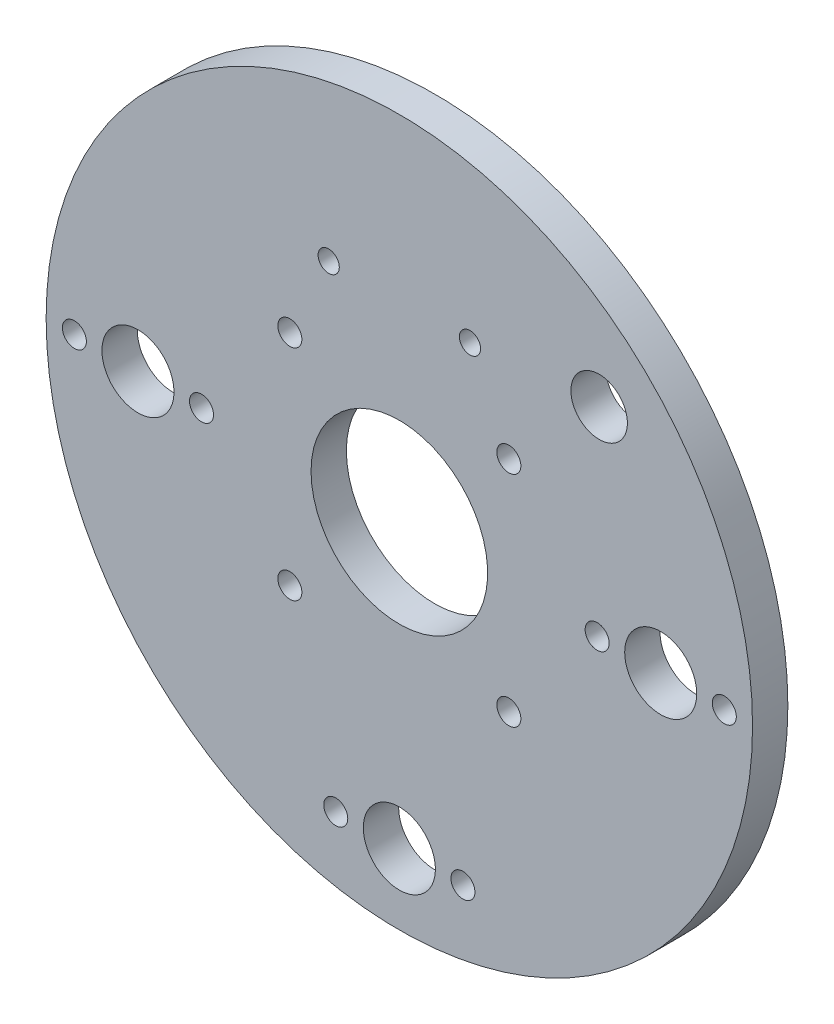
from build123d import *

# Parameters (mm, degrees)
SKETCH1_R                    = 50
BOSS_EXTRUDE1_DEPTH          = 5
F_25_0_25_DIAMETER_HOLE1_D   = 25
F_10_2_10_2_DIAMETER_HOLE1_D = 10.2
M3_CLEARANCE_HOLE1_D         = 3.4
M3_CLEARANCE_HOLE2_D         = 3.4
SKETCH11_R                   = 1.5
CUT_EXTRUDE1_DEPTH           = 10
SKETCH12_R                   = 4
CUT_EXTRUDE2_DEPTH           = 10


with BuildPart() as part:
    # Sketch1 → Boss-Extrude1 (new body)
    with BuildSketch(Plane.XY):
        Circle(SKETCH1_R)
    extrude(amount=BOSS_EXTRUDE1_DEPTH)

    # Ø25.0 (25) Diameter Hole1 (through all)
    with Locations(Plane(origin=(0, 0, 0), x_dir=(-1, 0, 0), z_dir=(0, 0, -1))):
        with Locations((0, 0)):
            Hole(F_25_0_25_DIAMETER_HOLE1_D / 2)

    # Ø10.2 (10.2) Diameter Hole1 (through all)
    with Locations(Plane(origin=(0, 0, 0), x_dir=(-1, 0, 0), z_dir=(0, 0, -1))):
        with Locations((37, 0), (-37, 0), (0, -40)):
            Hole(F_10_2_10_2_DIAMETER_HOLE1_D / 2)

    # M3 Clearance Hole1 (through all)
    with Locations(Plane.XY.offset(5)):
        with Locations((46, 0), (28, 0), (9, -40), (-9, -40), (-46, 0), (-28, 0)):
            Hole(M3_CLEARANCE_HOLE1_D / 2)

    # M3 Clearance Hole2 (through all)
    with Locations(Plane.XY.offset(5)):
        with Locations((15.5, 15.5), (15.5, -15.5), (-15.5, -15.5), (-15.5, 15.5)):
            Hole(M3_CLEARANCE_HOLE2_D / 2)

    # Sketch11 → Cut-Extrude1 (cut)
    with BuildSketch(Plane.XY.offset(5)):
        with Locations((-10, 27)):
            Circle(SKETCH11_R)
        with Locations((10, 27)):
            Circle(SKETCH11_R)
    extrude(amount=-CUT_EXTRUDE1_DEPTH, mode=Mode.SUBTRACT)

    # Sketch12 → Cut-Extrude2 (cut)
    with BuildSketch(Plane.XY.offset(5)):
        with Locations((28.284271247, 28.284271247)):
            Circle(SKETCH12_R)
    extrude(amount=-CUT_EXTRUDE2_DEPTH, mode=Mode.SUBTRACT)


solid = part.part
